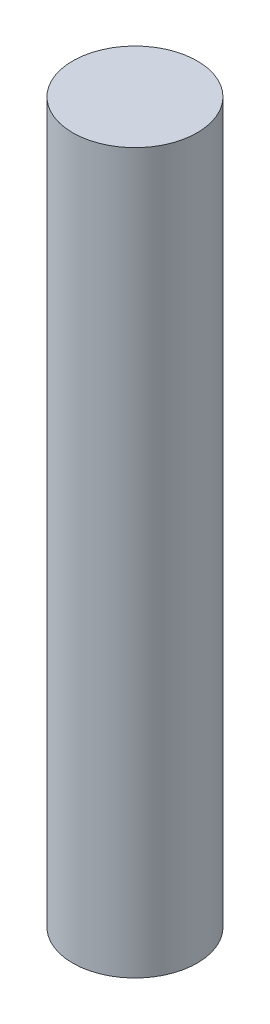
from build123d import *

# Parameters (mm, degrees)
SKETCH1_R           = 2
BOSS_EXTRUDE1_DEPTH = 11.55


with BuildPart() as part:
    # Sketch1 → Boss-Extrude1 (new body, symmetric)
    with BuildSketch(Plane(origin=(0, 0, 0), x_dir=(1, 0, 0), z_dir=(0, 1, 0))):
        Circle(SKETCH1_R)
    extrude(amount=BOSS_EXTRUDE1_DEPTH, both=True)


solid = part.part
